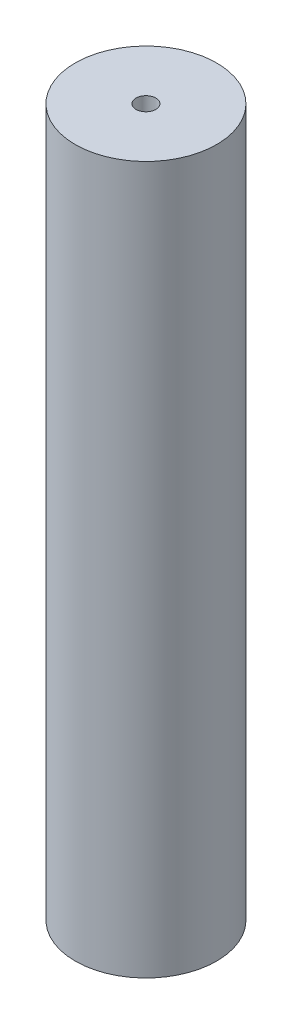
from build123d import *

# Parameters (mm, degrees)
SKETCH_1_R      = 2.5
SKETCH_1_R_2    = 0.35
EXTRUDE_3_DEPTH = 25


with BuildPart() as part:
    # Эскиз1 → Бобышка-Вытянуть3 (new body)
    with BuildSketch(Plane(origin=(0, 0, 0), x_dir=(1, 0, 0), z_dir=(0, 1, 0))):
        with Locations((-1.375025178, 1.385767562)):
            Circle(SKETCH_1_R)
        with Locations((-1.375025178, 1.385767562)):
            Circle(SKETCH_1_R_2, mode=Mode.SUBTRACT)
    extrude(amount=EXTRUDE_3_DEPTH)


solid = part.part
